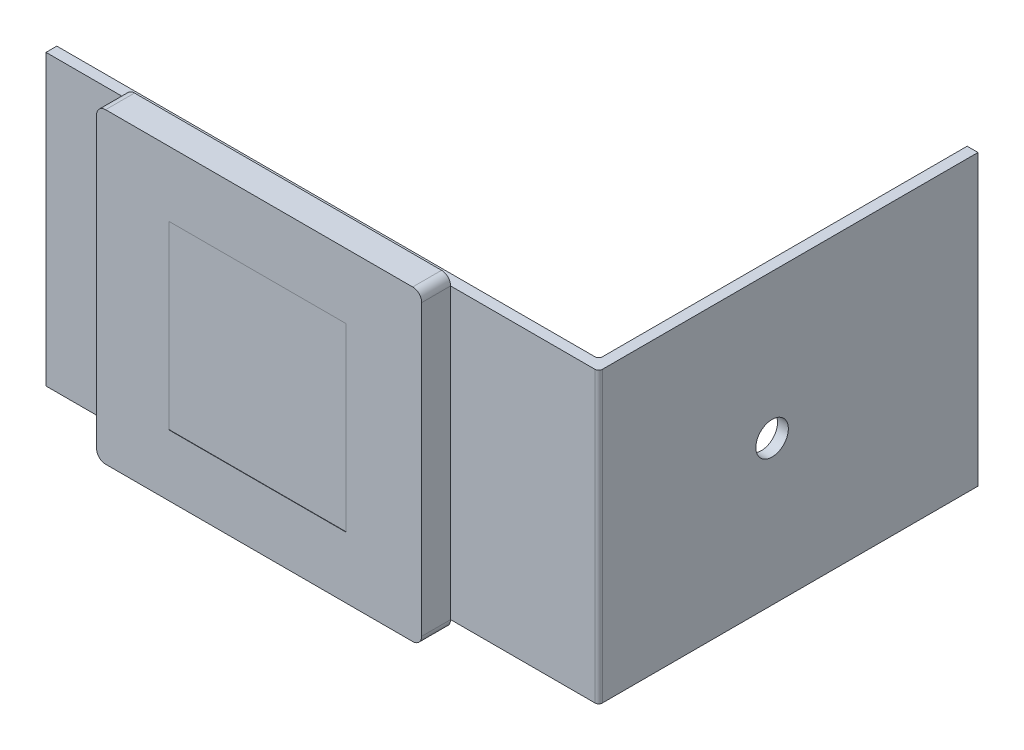
from build123d import *

# Parameters (mm, degrees)
AUFSATZ_LINEAR_AUSTRAGEN1_DEPTH      = 80
AUFSATZ_LINEAR_AUSTRAGEN2_DEPTH      = 8
SKIZZE3_W                            = 49
SKIZZE3_H                            = 50
AUFSATZ_LINEAR_AUSTRAGEN4_DEPTH      = 0.5
AUFSATZ_LINEAR_AUSTRAGEN4_DEPTH_BACK = 0.1
DURCHGANGSLOCH_F_R_M81_D             = 9


with BuildPart() as part:
    # Skizze1 → Aufsatz-Linear austragen1 (new body)
    with BuildSketch(Plane(origin=(0, 0, 0), x_dir=(1, 0, 0), z_dir=(0, 1, 0))):
        with BuildLine():
            Line((-154.797525399, -7.583806671), (-154.797525399, -10.583806671))
            Line((-154.797525399, -10.583806671), (-2.797525399, -10.583806671))
            ThreePointArc((-2.797525399, -10.583806671), (-2.090418618, -10.290913452), (-1.797525399, -9.583806671))
            Line((-1.797525399, -9.583806671), (-1.797525399, 94.416193329))
            Line((-1.797525399, 94.416193329), (-4.797525399, 94.416193329))
            Line((-4.797525399, 94.416193329), (-4.797525399, -6.583806671))
            ThreePointArc((-4.797525399, -6.583806671), (-5.090418618, -7.290913452), (-5.797525399, -7.583806671))
            Line((-5.797525399, -7.583806671), (-154.797525399, -7.583806671))
        make_face()
    extrude(amount=AUFSATZ_LINEAR_AUSTRAGEN1_DEPTH)

    # Skizze2 → Aufsatz-Linear austragen2 (add)
    with BuildSketch(Plane.XY.offset(10.583806671)):
        with BuildLine():
            Line((-45.297525399, -2.5), (-130.297525399, -2.5))
            ThreePointArc((-130.297525399, -2.5), (-132.065292352, -1.767766953), (-132.797525399, 0))
            Line((-132.797525399, 0), (-132.797525399, 80))
            ThreePointArc((-132.797525399, 80), (-132.065292352, 81.767766953), (-130.297525399, 82.5))
            Line((-130.297525399, 82.5), (-45.297525399, 82.5))
            ThreePointArc((-45.297525399, 82.5), (-43.529758446, 81.767766953), (-42.797525399, 80))
            Line((-42.797525399, 80), (-42.797525399, 0))
            ThreePointArc((-42.797525399, 0), (-43.529758446, -1.767766953), (-45.297525399, -2.5))
        make_face()
    extrude(amount=AUFSATZ_LINEAR_AUSTRAGEN2_DEPTH)


with BuildPart() as body_2:
    # Skizze3 → Aufsatz-Linear austragen4 (new body, two sides)
    with BuildSketch(Plane.XY.offset(18.583806671)) as aufsatz_linear_austragen4_sk:
        with Locations((-88.297525399, 39.5)):
            Rectangle(SKIZZE3_W, SKIZZE3_H)
    extrude(amount=AUFSATZ_LINEAR_AUSTRAGEN4_DEPTH)
    extrude(aufsatz_linear_austragen4_sk.sketch, amount=-AUFSATZ_LINEAR_AUSTRAGEN4_DEPTH_BACK)


with BuildPart() as part_1:
    add(part.part)

    # Kombinieren1: cut body 2
    add(body_2.part, mode=Mode.SUBTRACT)

    # Durchgangsloch für M81 (through all)
    with Locations(Plane(origin=(-1.797525399, 0, 0), x_dir=(0, 0, -1), z_dir=(1, 0, 0))):
        with Locations((37.416193329, 40)):
            Hole(DURCHGANGSLOCH_F_R_M81_D / 2)


solid = part_1.part
